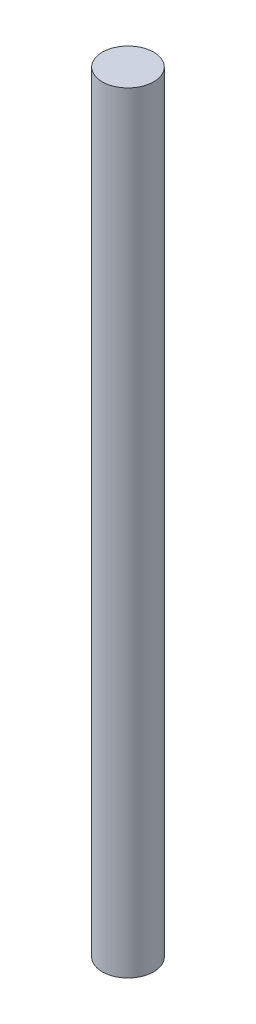
from build123d import *

# Parameters (mm, degrees)
SKETCH1_R           = 50
BOSS_EXTRUDE1_DEPTH = 1500


with BuildPart() as part:
    # Sketch1 → Boss-Extrude1 (new body)
    with BuildSketch(Plane(origin=(0, 0, 0), x_dir=(1, 0, 0), z_dir=(0, 1, 0))):
        Circle(SKETCH1_R)
    extrude(amount=-BOSS_EXTRUDE1_DEPTH)


solid = part.part
